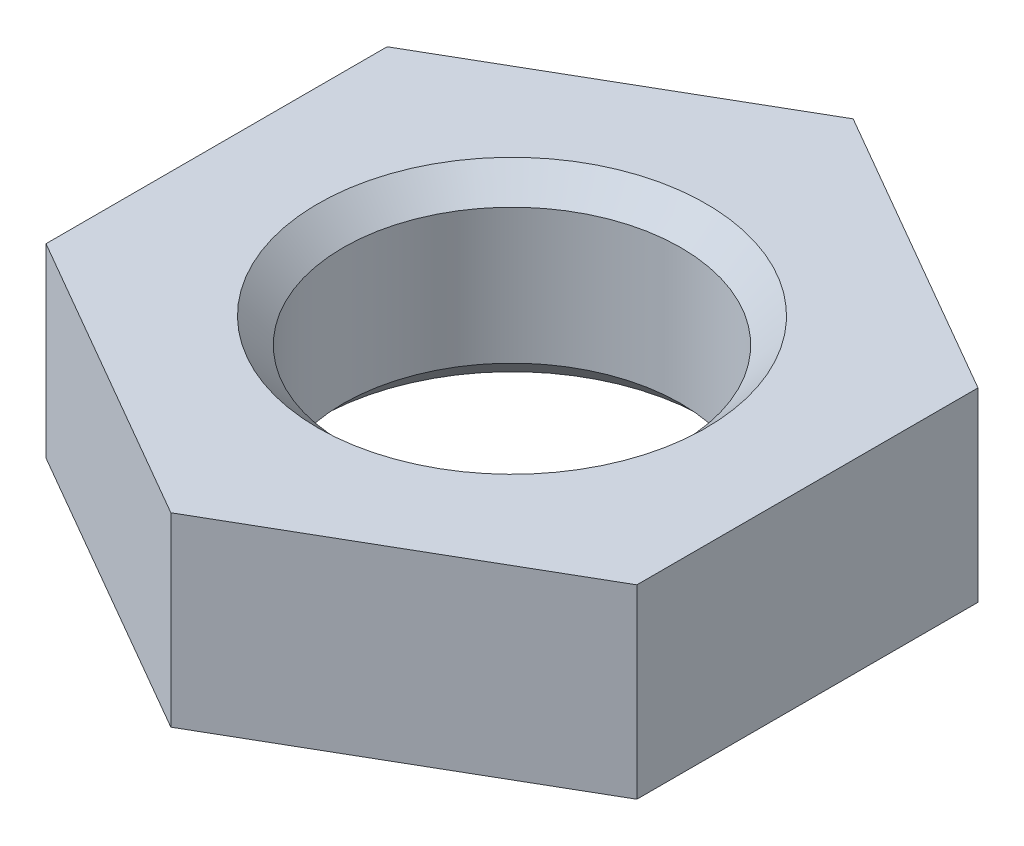
from build123d import *

# Parameters (mm, degrees)
SKETCH_1_R      = 2
EXTRUDE_1_DEPTH = 2.2
CHAMFER_1_SIZE  = 0.3


with BuildPart() as part:
    # Эскиз1 → Бобышка-Вытянуть1 (new body)
    with BuildSketch(Plane(origin=(0, 0, 0), x_dir=(1, 0, 0), z_dir=(0, 1, 0))):
        Polygon((-3.5, 2.020725942), (-3.5, -2.020725942), (0, -4.041451884), (3.5, -2.020725942), (3.5, 2.020725942), (0, 4.041451884), align=None)
        Circle(SKETCH_1_R, mode=Mode.SUBTRACT)
    extrude(amount=EXTRUDE_1_DEPTH)

    # Фаска1
    chamfer_1_edges = [part.edges().sort_by_distance(p)[0] for p in [
        (-2, 0, 0),
        (-2, 2.2, 0),
    ]]
    chamfer(chamfer_1_edges, length=CHAMFER_1_SIZE)


solid = part.part
